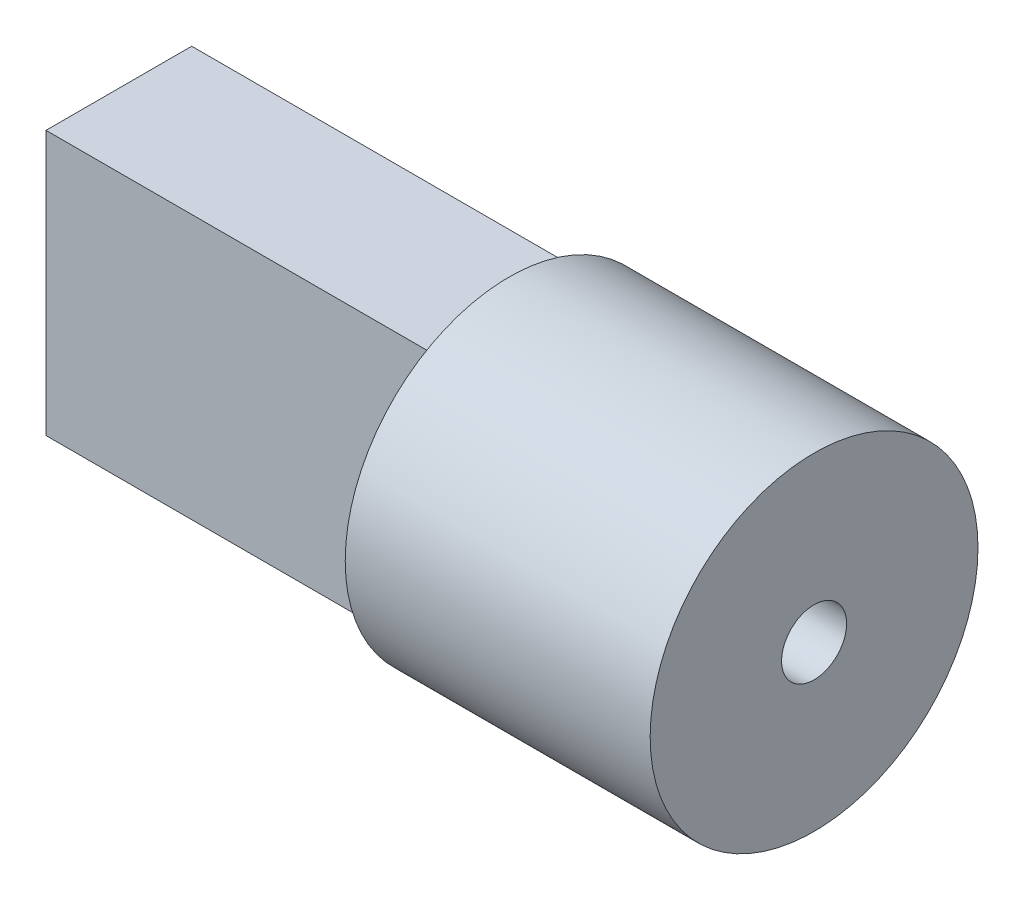
from build123d import *

# Parameters (mm, degrees)
SKETCH1_R      = 4.0005
SKETCH1_R_2    = 0.79375
EXTRUDE1_DEPTH = 7.4422
SKETCH4_W      = 3.556
SKETCH4_H      = 6.4516
EXTRUDE2_DEPTH = 9.525


with BuildPart() as part:
    # Sketch1 → Extrude1 (new body)
    with BuildSketch(Plane(origin=(0, 0, 0), x_dir=(0, 0, -1), z_dir=(1, 0, 0))):
        Circle(SKETCH1_R)
        Circle(SKETCH1_R_2, mode=Mode.SUBTRACT)
    extrude(amount=-EXTRUDE1_DEPTH)

    # Sketch4 → Extrude2 (add)
    with BuildSketch(Plane.ZY.offset(7.4422)):
        Rectangle(SKETCH4_W, SKETCH4_H)
    extrude(amount=EXTRUDE2_DEPTH)


solid = part.part
